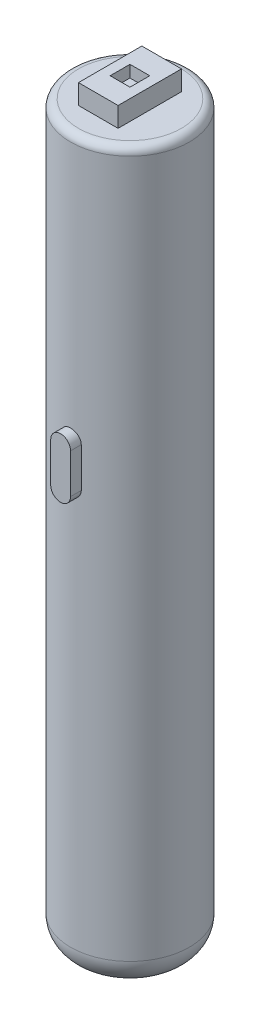
from build123d import *

# Parameters (mm, degrees)
SKETCH1_R                = 15
BOSS_EXTRUDE1_DEPTH      = 185
FILLET2_R                = 7
FILLET3_R                = 2
SKETCH2_R                = 6
CUT_EXTRUDE1_DEPTH       = 180
BOSS_EXTRUDE3_DEPTH      = 2.5
BOSS_EXTRUDE3_DEPTH_BACK = 32.5
BOSS_EXTRUDE4_START      = 185
BOSS_EXTRUDE4_DEPTH      = 5
CUT_EXTRUDE3_DEPTH       = 3


with BuildPart() as part:
    # Sketch1 → Boss-Extrude1 (new body)
    with BuildSketch(Plane(origin=(0, 0, 0), x_dir=(1, 0, 0), z_dir=(0, 1, 0))):
        Circle(SKETCH1_R)
    extrude(amount=BOSS_EXTRUDE1_DEPTH)

    # Fillet2
    fillet2_edges = [part.edges().sort_by_distance(p)[0] for p in [
        (-15, 0, 0),
    ]]
    fillet(fillet2_edges, radius=FILLET2_R)

    # Fillet3
    fillet3_edges = [part.edges().sort_by_distance(p)[0] for p in [
        (-15, 185, 0),
    ]]
    fillet(fillet3_edges, radius=FILLET3_R)

    # Sketch2 → Cut-Extrude1 (cut)
    with BuildSketch(Plane(origin=(0, 0, 0), x_dir=(1, 0, 0), z_dir=(0, 1, 0))):
        Circle(SKETCH2_R)
    extrude(amount=CUT_EXTRUDE1_DEPTH, mode=Mode.SUBTRACT)

    # Sketch7 → Boss-Extrude3 (add, two sides)
    with BuildSketch(Plane.XY.offset(15)) as boss_extrude3_sk:
        with BuildLine():
            Line((2.5, 113), (2.5, 118))
            ThreePointArc((2.5, 118), (0, 120.5), (-2.5, 118))
            Line((-2.5, 118), (-2.5, 113))
            Line((-2.5, 113), (-2.5, 108))
            ThreePointArc((-2.5, 108), (0, 105.5), (2.5, 108))
            Line((2.5, 108), (2.5, 113))
        make_face()
    extrude(amount=BOSS_EXTRUDE3_DEPTH)
    extrude(boss_extrude3_sk.sketch, amount=-BOSS_EXTRUDE3_DEPTH_BACK)

    # Sketch8 → Boss-Extrude4 (add)
    with BuildSketch(Plane(origin=(0, 0, 0), x_dir=(1, 0, 0), z_dir=(0, 1, 0)).offset(BOSS_EXTRUDE4_START)):
        Polygon((0, 8), (-5, 8), (-5, 0), (-5, -8), (0, -8), (5, -8), (5, 0), (5, 8), align=None)
    extrude(amount=BOSS_EXTRUDE4_DEPTH)

    # Sketch10 → Cut-Extrude3 (cut)
    with BuildSketch(Plane(origin=(0, 190, 0), x_dir=(1, 0, 0), z_dir=(0, 1, 0))):
        Polygon((0, -2.5), (2.5, -2.5), (2.5, 2.5), (0, 2.5), (-2.5, 2.5), (-2.5, -2.5), align=None)
    extrude(amount=-CUT_EXTRUDE3_DEPTH, mode=Mode.SUBTRACT)


solid = part.part
